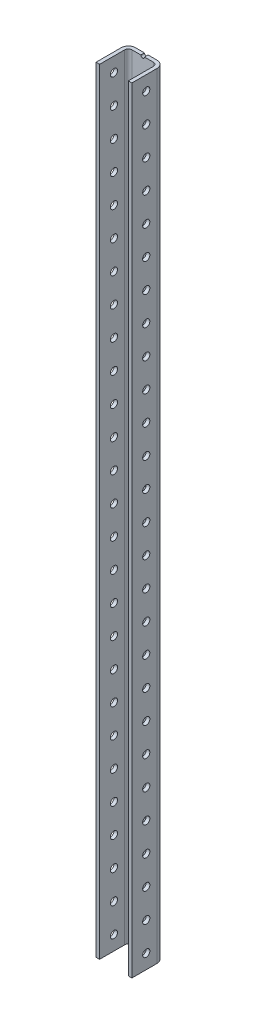
from build123d import *

# Parameters (mm, degrees)
EXTRUDE1_DEPTH              = 342.9
SKETCH2_R                   = 1.58758
SKETCH2_R_2                 = 4.826
EXTRUDE2_DEPTH              = 25
F_1_4_0_25_DIAMETER_HOLE1_D = 6.35
LPATTERN1_COUNT             = 27
LPATTERN1_PITCH             = 25.4


with BuildPart() as part:
    # Sketch1 → Extrude1 (new body, symmetric)
    with BuildSketch(Plane(origin=(0, 0, 0), x_dir=(1, 0, 0), z_dir=(0, 1, 0))):
        with BuildLine():
            Line((-12.7, 0), (-12.7, 22.225))
            ThreePointArc((-12.7, 22.225), (-11.77006403, 24.47006403), (-9.525, 25.4))
            Line((-9.525, 25.4), (9.525, 25.4))
            ThreePointArc((9.525, 25.4), (11.77006403, 24.47006403), (12.7, 22.225))
            Line((12.7, 22.225), (12.7, 0))
            Line((12.7, 0), (15.875, 0))
            Line((15.875, 0), (15.875, 22.225))
            ThreePointArc((15.875, 22.225), (14.015128061, 26.715128061), (9.525, 28.575))
            Line((9.525, 28.575), (-9.525, 28.575))
            ThreePointArc((-9.525, 28.575), (-14.015128061, 26.715128061), (-15.875, 22.225))
            Line((-15.875, 22.225), (-15.875, 0))
            Line((-15.875, 0), (-12.7, 0))
        make_face()
    extrude(amount=EXTRUDE1_DEPTH, both=True)

    # Sketch2 → Extrude2 (cut)
    with BuildSketch(Plane(origin=(0, 0, -28.575), x_dir=(-1, 0, 0), z_dir=(0, 0, -1))):
        with Locations((0, 342.9)):
            Circle(SKETCH2_R)
        with Locations((-1.905, 209.55)):
            Circle(SKETCH2_R_2)
        with Locations((-1.905, 184.15)):
            Circle(SKETCH2_R_2)
        with Locations((-1.905, -6.35)):
            Circle(SKETCH2_R_2)
        with Locations((1.905, 101.6)):
            Circle(SKETCH2_R_2)
        with Locations((-1.905, -260.35)):
            Circle(SKETCH2_R_2)
        with Locations((-1.905, -234.95)):
            Circle(SKETCH2_R_2)
        with Locations((-1.905, 19.05)):
            Circle(SKETCH2_R_2)
    extrude(amount=-EXTRUDE2_DEPTH, mode=Mode.SUBTRACT)

    # 1/4 (0.25) Diameter Hole1 (through all)
    with Locations(Plane.ZY.offset(15.875)):
        with Locations((-12.7, 330.2)):
            f_1_4_0_25_diameter_hole1 = Hole(F_1_4_0_25_DIAMETER_HOLE1_D / 2)

    # LPattern1: 1/4 (0.25) Diameter Hole1 ×27
    with Locations(*[(0, -i * LPATTERN1_PITCH, 0) for i in range(1, LPATTERN1_COUNT)]):
        add(f_1_4_0_25_diameter_hole1, mode=Mode.SUBTRACT)


solid = part.part
